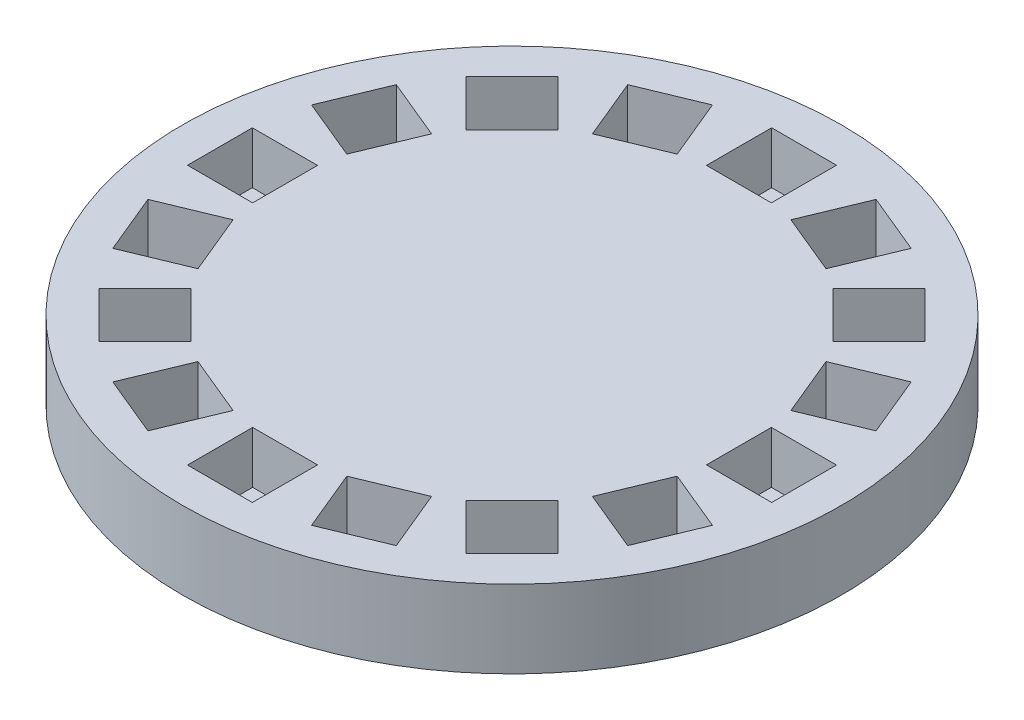
from build123d import *

# Parameters (mm, degrees)
SKETCH1_R           = 63.5
BOSS_EXTRUDE1_DEPTH = 14.973360437
SKETCH2_W           = 12.5
SKETCH2_H           = 12.56
CUT_EXTRUDE1_DEPTH  = 10
CIRPATTERN1_COUNT   = 16


with BuildPart() as part:
    # Sketch1 → Boss-Extrude1 (new body)
    with BuildSketch(Plane(origin=(0, 0, 0), x_dir=(1, 0, 0), z_dir=(0, 1, 0))):
        Circle(SKETCH1_R)
    extrude(amount=BOSS_EXTRUDE1_DEPTH)

    # Sketch2 → Cut-Extrude1 (cut)
    with BuildSketch(Plane(origin=(0, 14.973360437, 0), x_dir=(1, 0, 0), z_dir=(0, 1, 0))):
        with Locations((0, -50)):
            Rectangle(SKETCH2_W, SKETCH2_H)
    cut_extrude1 = extrude(amount=-CUT_EXTRUDE1_DEPTH, mode=Mode.SUBTRACT)

    # CirPattern1: Cut-Extrude1 ×16 about axis
    cirpattern1_axis = Axis((0, 0, 0), (0, 1, 0))
    for i in range(1, CIRPATTERN1_COUNT):
        add(cut_extrude1.rotate(cirpattern1_axis, i * 360 / CIRPATTERN1_COUNT), mode=Mode.SUBTRACT)


solid = part.part
